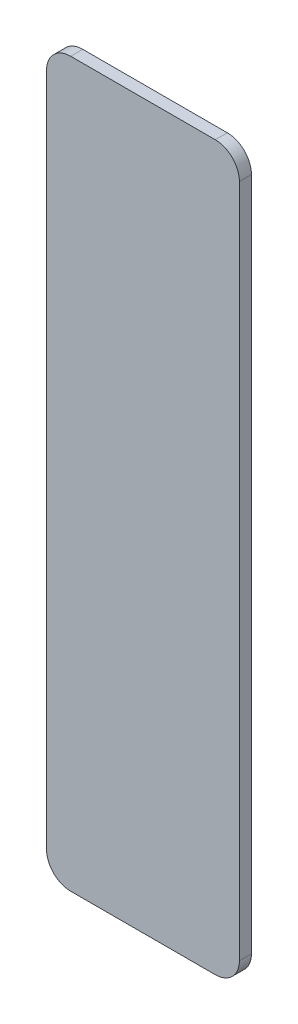
from build123d import *

# Parameters (mm, degrees)
SKETCH1_W           = 8
SKETCH1_H           = 30
BOSS_EXTRUDE1_DEPTH = 0.5
FILLET1_R           = 1


with BuildPart() as part:
    # Sketch1 → Boss-Extrude1 (new body)
    with BuildSketch(Plane.XY):
        Rectangle(SKETCH1_W, SKETCH1_H)
    extrude(amount=BOSS_EXTRUDE1_DEPTH)

    # Fillet1
    fillet1_edges = [part.edges().sort_by_distance(p)[0] for p in [
        (4, -15, 0.25),
        (-4, -15, 0.25),
        (-4, 15, 0.25),
        (4, 15, 0.25),
    ]]
    fillet(fillet1_edges, radius=FILLET1_R)


solid = part.part
